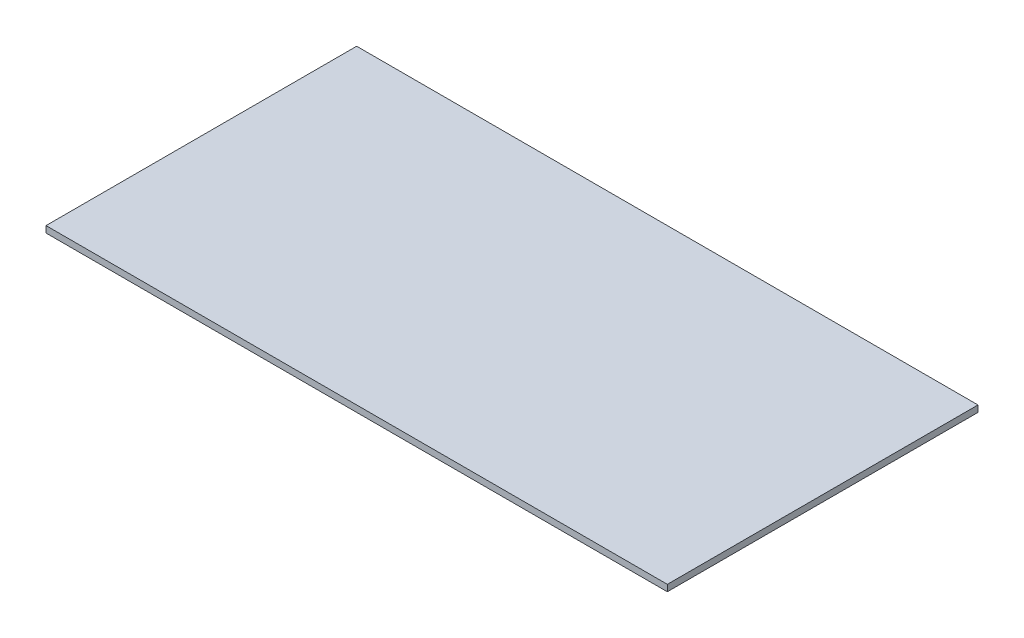
from build123d import *

# Parameters (mm, degrees)
SKETCH1_W           = 609.6
SKETCH1_H           = 304.8
BOSS_EXTRUDE1_DEPTH = 3.175


with BuildPart() as part:
    # Sketch1 → Boss-Extrude1 (new body, symmetric)
    with BuildSketch(Plane(origin=(0, 0, 0), x_dir=(1, 0, 0), z_dir=(0, 1, 0))):
        Rectangle(SKETCH1_W, SKETCH1_H)
    extrude(amount=BOSS_EXTRUDE1_DEPTH, both=True)


solid = part.part
